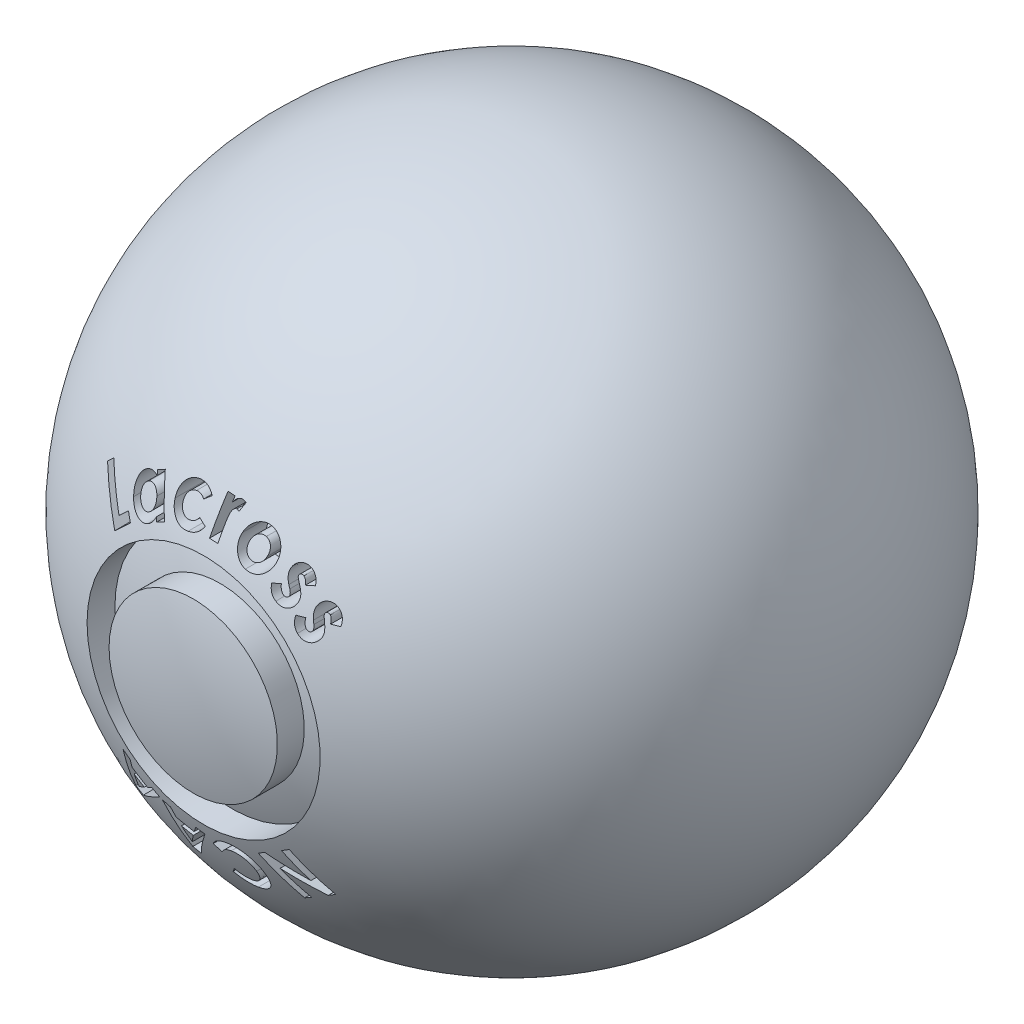
from build123d import *
from build123d.topology import SkipClean

# Parameters (mm, degrees)
LOGO_REACH      = 85.976
LOGO_END_RADIUS = 29.7942
SKETCH3_R       = 11.43
SKETCH3_R_2     = 8.255


with BuildPart() as part:
    # Sketch1 → base (revolve)
    with SkipClean():  # the faces are left unmerged after this step: merging them gives an invalid solid
        with BuildSketch(Plane.XY):
            with BuildLine():
                ThreePointArc((32.3342, 0), (22.863732084, 22.863732084), (0, 32.3342))
                Line((0, 32.3342), (0, -32.3342))
                ThreePointArc((0, -32.3342), (22.863732084, -22.863732084), (32.3342, 0))
            make_face()
            with BuildLine():
                Line((0, -32.3342), (0, 32.3342))
                ThreePointArc((0, 32.3342), (-32.3342, 0), (0, -32.3342))
            make_face()
        revolve(axis=Axis((0, 32.3342, 0), (0, -1, 0)))

    # logo: up to this sphere (the profile starts outside it)
    with SkipClean():  # the faces are left unmerged after this step: merging them gives an invalid solid
        logo_end = Location((0, 0, 0)) * Sphere(LOGO_END_RADIUS, mode=Mode.PRIVATE)
        # Sketch3 → logo (cut, up to the surface)
        with BuildSketch(Plane.XY.offset(38.1), mode=Mode.PRIVATE) as logo_sk1:
            with Locations(Location((0, 0, 0), (0, 0, 180))):
                Circle(SKETCH3_R)
            with Locations(Location((0, 0, 0), (0, 0, 180))):
                Circle(SKETCH3_R_2, mode=Mode.SUBTRACT)
        logo_tool1 = extrude(logo_sk1.sketch, amount=-LOGO_REACH, mode=Mode.PRIVATE) - logo_end
        add(logo_tool1.solids().sort_by_distance((11.106711, 0, 38.1))[0], mode=Mode.SUBTRACT)
        # Sketch3 → logo (cut, up to the surface)
        with BuildSketch(Plane.XY.offset(38.1), mode=Mode.PRIVATE) as logo_sk2:
            Polygon((-12.220194216, 11.952999391), (-11.59689694, 12.526432884), (-9.132201427, 9.846254599), (-8.223968254, 10.681472949), (-7.677247501, 10.086669263), (-9.20877795, 8.67801742), align=None)
        logo_tool2 = extrude(logo_sk2.sketch, amount=-LOGO_REACH, mode=Mode.PRIVATE) - logo_end
        add(logo_tool2.solids().sort_by_distance((-9.984775, 10.4692, 38.1))[0], mode=Mode.SUBTRACT)
        # Sketch3 → logo (cut, up to the surface)
        with BuildSketch(Plane.XY.offset(38.1), mode=Mode.PRIVATE) as logo_sk3:
            with BuildLine():
                Line((-6.575748347, 14.406590874), (-5.849161809, 14.784130938))
                Line((-5.849161809, 14.784130938), (-4.336330278, 11.877784784))
                Line((-4.336330278, 11.877784784), (-5.062916817, 11.50024472))
                Line((-5.062916817, 11.50024472), (-5.223193259, 11.807441234))
                add(Edge.make_bspline(
                    [(-5.223193259, 11.807441234), (-5.241626062, 11.756927378), (-5.277224447, 11.659372401), (-5.343199774, 11.522802371), (-5.415401381, 11.399777962), (-5.496691127, 11.290283693), (-5.586989432, 11.192801259), (-5.687387444, 11.105276293), (-5.798002488, 11.026348034), (-5.878076171, 10.982138714), (-5.918614934, 10.959756939)],
                    knots=[0, 0, 0, 0, 1.145109462, 2.21149471, 3.226674917, 4.180365656, 5.11119938, 6.052373645, 7.013978618, 8, 8, 8, 8], degree=3))
                add(Edge.make_bspline(
                    [(-5.918614934, 10.959756939), (-5.965704409, 10.937165483), (-6.058689034, 10.892555553), (-6.203905372, 10.842303191), (-6.35151192, 10.809393018), (-6.501364993, 10.792239337), (-6.653576791, 10.791612971), (-6.808523952, 10.806668483), (-6.965376421, 10.839671447), (-7.122933287, 10.886228428), (-7.276659987, 10.947900363), (-7.422704727, 11.024110008), (-7.559553322, 11.113269591), (-7.686635337, 11.216538136), (-7.804387818, 11.332558835), (-7.912772349, 11.461990517), (-8.012249912, 11.604492542), (-8.068748458, 11.707737443), (-8.097484125, 11.760248726)],
                    knots=[0, 0, 0, 0, 0.970234887, 1.915861843, 2.848753918, 3.776017437, 4.713904148, 5.672922253, 6.66399809, 7.688610075, 8.723316567, 9.737493544, 10.74587694, 11.75395846, 12.776057297, 13.813715798, 14.888036237, 16, 16, 16, 16], degree=3))
                add(Edge.make_bspline(
                    [(-8.097484125, 11.760248726), (-8.124898759, 11.815609134), (-8.178799867, 11.924455646), (-8.241032572, 12.092017225), (-8.290077093, 12.25770927), (-8.3184663, 12.422993037), (-8.333831545, 12.587124198), (-8.330701427, 12.75004546), (-8.312134103, 12.912094131), (-8.27632141, 13.070864421), (-8.227070437, 13.224193593), (-8.164381011, 13.368054335), (-8.090613026, 13.502131875), (-8.002590989, 13.624267163), (-7.903346281, 13.736622694), (-7.791133406, 13.837508705), (-7.666957866, 13.92849635), (-7.576290765, 13.978662921), (-7.530283604, 14.004118919)],
                    knots=[0, 0, 0, 0, 1.146589111, 2.254358864, 3.315174153, 4.351062424, 5.363677002, 6.372578805, 7.371537763, 8.387971139, 9.390331128, 10.358080331, 11.298261005, 12.226782769, 13.148291144, 14.077156464, 15.02429247, 16, 16, 16, 16], degree=3))
                add(Edge.make_bspline(
                    [(-7.530283604, 14.004118919), (-7.486714404, 14.025112987), (-7.400336498, 14.066734677), (-7.265419456, 14.114470966), (-7.127456306, 14.145015559), (-6.987702481, 14.163316919), (-6.845308343, 14.167008236), (-6.700760859, 14.154724526), (-6.55377864, 14.129580037), (-6.457366973, 14.100714208), (-6.408348508, 14.086037989)],
                    knots=[0, 0, 0, 0, 1.003475627, 1.98943578, 2.962432789, 3.931422823, 4.911339355, 5.912637565, 6.938724877, 8, 8, 8, 8], degree=3))
                Line((-6.408348508, 14.086037989), (-6.575748347, 14.406590874))
            make_face()
            with BuildLine():
                add(Edge.make_bspline(
                    [(-7.030755359, 13.409315233), (-7.058052705, 13.394064398), (-7.111746412, 13.364066105), (-7.186203033, 13.311469532), (-7.251900765, 13.252097941), (-7.311721841, 13.188885995), (-7.362674928, 13.118600322), (-7.405950905, 13.042839813), (-7.443300235, 12.962084502), (-7.470886849, 12.87613326), (-7.492055625, 12.7874909), (-7.501869801, 12.697257627), (-7.505746496, 12.606577076), (-7.496412645, 12.515441143), (-7.481189371, 12.423394458), (-7.454441783, 12.331268155), (-7.419938932, 12.238216448), (-7.390420831, 12.177627877), (-7.375349709, 12.146693037)],
                    knots=[0, 0, 0, 0, 1.024115946, 2.014429524, 2.978712035, 3.92142172, 4.860915671, 5.815042886, 6.77682121, 7.770138417, 8.7680152, 9.757134333, 10.739778378, 11.735567947, 12.752408901, 13.793014357, 14.873174473, 16, 16, 16, 16], degree=3))
                add(Edge.make_bspline(
                    [(-7.375349709, 12.146693037), (-7.358563278, 12.116463927), (-7.325586961, 12.057079974), (-7.269753918, 11.973966735), (-7.207574171, 11.899508634), (-7.140914567, 11.832638665), (-7.069414392, 11.773467302), (-6.992918283, 11.722442609), (-6.911943415, 11.678176845), (-6.825734099, 11.644439601), (-6.738102921, 11.617228636), (-6.649702573, 11.60024018), (-6.561933754, 11.593200999), (-6.475100486, 11.594873681), (-6.388887789, 11.605784085), (-6.303159195, 11.625320656), (-6.217918546, 11.654655203), (-6.163510969, 11.681575498), (-6.135878556, 11.695247725)],
                    knots=[0, 0, 0, 0, 1.125340342, 2.210688943, 3.253575218, 4.27840149, 5.280474548, 6.269324221, 7.267944258, 8.278090076, 9.277597838, 10.251608216, 11.201649133, 12.139077343, 13.073862727, 14.025474609, 14.997181906, 16, 16, 16, 16], degree=3))
                add(Edge.make_bspline(
                    [(-6.135878556, 11.695247725), (-6.107990907, 11.710803382), (-6.0534839, 11.741207246), (-5.977879321, 11.794042482), (-5.910501733, 11.853297238), (-5.851146728, 11.918555558), (-5.797639754, 11.988251138), (-5.753191668, 12.064375984), (-5.716675585, 12.146025719), (-5.687435128, 12.23216817), (-5.665929673, 12.321505378), (-5.654206754, 12.412880447), (-5.652884458, 12.505047115), (-5.659333369, 12.598294271), (-5.678400164, 12.691833459), (-5.703542026, 12.787016694), (-5.740675243, 12.882341079), (-5.771235356, 12.944728605), (-5.786832081, 12.976568838)],
                    knots=[0, 0, 0, 0, 1.028705706, 2.01062732, 2.966291609, 3.914120285, 4.84965696, 5.79298585, 6.747740096, 7.727842861, 8.720884071, 9.704481639, 10.689938034, 11.6877134, 12.710173653, 13.761403936, 14.857505237, 16, 16, 16, 16], degree=3))
                add(Edge.make_bspline(
                    [(-5.786832081, 12.976568838), (-5.803506529, 13.007167019), (-5.836223991, 13.067204675), (-5.893447988, 13.14989661), (-5.955162071, 13.224368823), (-6.021295505, 13.290596119), (-6.092006856, 13.349161607), (-6.168044202, 13.398891457), (-6.248530856, 13.441544872), (-6.333830031, 13.47348259), (-6.420586288, 13.499037787), (-6.508447926, 13.513881802), (-6.595848714, 13.520606491), (-6.683309124, 13.516625927), (-6.770681643, 13.504108195), (-6.858215184, 13.482816019), (-6.945609913, 13.451280393), (-7.001917353, 13.423528459), (-7.030755359, 13.409315233)],
                    knots=[0, 0, 0, 0, 1.131426828, 2.220008364, 3.260776545, 4.269884806, 5.256349188, 6.237852751, 7.216890221, 8.208946876, 9.19172847, 10.150808942, 11.098184545, 12.034304975, 12.988866843, 13.961759516, 14.95610973, 16, 16, 16, 16], degree=3))
            make_face(mode=Mode.SUBTRACT)
        logo_tool3 = extrude(logo_sk3.sketch, amount=-LOGO_REACH, mode=Mode.PRIVATE) - logo_end
        add(logo_tool3.solids().sort_by_distance((-6.186415, 14.545246, 38.1))[0], mode=Mode.SUBTRACT)
        # Sketch3 → logo (cut, up to the surface)
        with BuildSketch(Plane.XY.offset(38.1), mode=Mode.PRIVATE) as logo_sk4:
            with BuildLine():
                Line((-0.887055771, 15.204264211), (-1.495215827, 14.724325308))
                add(Edge.make_bspline(
                    [(-1.495215827, 14.724325308), (-1.531236286, 14.750302707), (-1.600157891, 14.800007904), (-1.707325266, 14.859864087), (-1.810707197, 14.906419163), (-1.913488852, 14.937239176), (-2.017526797, 14.955217444), (-2.126150101, 14.962271535), (-2.240998154, 14.957659223), (-2.318935088, 14.94645028), (-2.358927766, 14.940698506)],
                    knots=[0, 0, 0, 0, 1.157927751, 2.215580876, 3.196958254, 4.11086407, 5.007242523, 5.94639553, 6.946210253, 8, 8, 8, 8], degree=3))
                add(Edge.make_bspline(
                    [(-2.358927766, 14.940698506), (-2.395587857, 14.933949134), (-2.467274119, 14.920751206), (-2.570332141, 14.889962464), (-2.666575812, 14.851799169), (-2.756093352, 14.806307366), (-2.838883469, 14.753416693), (-2.914591114, 14.69272713), (-2.983866599, 14.624681015), (-3.044864828, 14.549054909), (-3.097899818, 14.468363037), (-3.143163634, 14.384344756), (-3.17781015, 14.296736128), (-3.203275063, 14.205755229), (-3.217858121, 14.111303736), (-3.22435059, 14.013556001), (-3.220697104, 13.912744575), (-3.211358134, 13.845117653), (-3.206612061, 13.810749587)],
                    knots=[0, 0, 0, 0, 1.126958784, 2.203689632, 3.247420436, 4.255315036, 5.236623827, 6.213981355, 7.185381852, 8.168373322, 9.14704971, 10.103015897, 11.050043467, 11.991093346, 12.954995786, 13.935688241, 14.950914819, 16, 16, 16, 16], degree=3))
                add(Edge.make_bspline(
                    [(-3.206612061, 13.810749587), (-3.200083815, 13.77736484), (-3.187299449, 13.711986967), (-3.158403997, 13.618166662), (-3.122994751, 13.530233798), (-3.079218135, 13.448604915), (-3.026857763, 13.373657918), (-2.96850055, 13.303466263), (-2.900566551, 13.241315517), (-2.827301359, 13.184038116), (-2.747294897, 13.135562985), (-2.663014734, 13.094941854), (-2.574568546, 13.063880508), (-2.4823942, 13.041517038), (-2.386356365, 13.02823971), (-2.28648784, 13.023694034), (-2.182825465, 13.029414975), (-2.113112581, 13.03913564), (-2.077553567, 13.044093938)],
                    knots=[0, 0, 0, 0, 1.063594057, 2.082852897, 3.065721664, 4.02542117, 4.973278218, 5.922044483, 6.874665232, 7.847880727, 8.827278234, 9.794985254, 10.770015254, 11.754199014, 12.757471331, 13.798491988, 14.877059044, 16, 16, 16, 16], degree=3))
                add(Edge.make_bspline(
                    [(-2.077553567, 13.044093938), (-2.034004239, 13.052401777), (-1.948836839, 13.068649032), (-1.82756247, 13.10750495), (-1.715093204, 13.15552082), (-1.612417067, 13.214170328), (-1.519407949, 13.283880305), (-1.435672586, 13.36323151), (-1.360410664, 13.452745625), (-1.319849024, 13.519589726), (-1.299322398, 13.553416855)],
                    knots=[0, 0, 0, 0, 1.10374896, 2.158550613, 3.165502063, 4.146038512, 5.097044931, 6.054327365, 7.015372806, 8, 8, 8, 8], degree=3))
                Line((-1.299322398, 13.553416855), (-0.592325202, 13.225740573))
                add(Edge.make_bspline(
                    [(-0.592325202, 13.225740573), (-0.62737299, 13.164832686), (-0.696305076, 13.045038886), (-0.824078853, 12.883238537), (-0.967931202, 12.74009535), (-1.128739844, 12.6152888), (-1.306247104, 12.50941634), (-1.501392532, 12.424491081), (-1.712397879, 12.355610181), (-1.860786763, 12.326889887), (-1.936866468, 12.312164852)],
                    knots=[0, 0, 0, 0, 0.998240525, 1.963342229, 2.921403494, 3.87798527, 4.85087333, 5.85242791, 6.898929304, 8, 8, 8, 8], degree=3))
                add(Edge.make_bspline(
                    [(-1.936866468, 12.312164852), (-2.005892356, 12.302048093), (-2.140506613, 12.282318394), (-2.339954901, 12.273679497), (-2.530112353, 12.282251677), (-2.71186019, 12.307954206), (-2.884888205, 12.351282759), (-3.049205671, 12.41314979), (-3.204042373, 12.492980299), (-3.348689009, 12.589121997), (-3.481298404, 12.698212219), (-3.600934547, 12.81631616), (-3.708007767, 12.940860111), (-3.798992234, 13.074831951), (-3.877215912, 13.215858981), (-3.940065562, 13.365633623), (-3.991208264, 13.522381579), (-4.011834214, 13.631190455), (-4.022241067, 13.686090132)],
                    knots=[0, 0, 0, 0, 1.196219795, 2.332867314, 3.418648779, 4.45776986, 5.476632145, 6.472497083, 7.463141199, 8.458784809, 9.446532586, 10.404307894, 11.339912548, 12.259359812, 13.17779133, 14.101809662, 15.042265299, 16, 16, 16, 16], degree=3))
                add(Edge.make_bspline(
                    [(-4.022241067, 13.686090132), (-4.028133434, 13.724608724), (-4.039831665, 13.801080437), (-4.047581617, 13.916291973), (-4.047409985, 14.030194089), (-4.040570959, 14.143284493), (-4.025136695, 14.255063802), (-4.003191378, 14.36587018), (-3.972410561, 14.475257513), (-3.934367388, 14.583234729), (-3.889142421, 14.688838965), (-3.837283275, 14.790487557), (-3.779675464, 14.888468682), (-3.712847637, 14.980391645), (-3.642388484, 15.070268023), (-3.562974893, 15.153706175), (-3.478603182, 15.234415747), (-3.386894208, 15.309504033), (-3.290381303, 15.380046999), (-3.188070424, 15.443056104), (-3.08258139, 15.501073401), (-2.97238417, 15.552423442), (-2.85732233, 15.595196424), (-2.739084285, 15.634039715), (-2.61619422, 15.665421828), (-2.532364853, 15.680833554), (-2.489820194, 15.688655236)],
                    knots=[0, 0, 0, 0, 0.995950414, 1.97727983, 2.948640864, 3.906749746, 4.871596994, 5.831537396, 6.79264694, 7.77429907, 8.756801484, 9.727450811, 10.69053567, 11.659165654, 12.631000869, 13.608154772, 14.601238803, 15.614671913, 16.63625518, 17.655439798, 18.684437337, 19.713210985, 20.760404607, 21.821149039, 22.894200504, 24, 24, 24, 24], degree=3))
                add(Edge.make_bspline(
                    [(-2.489820194, 15.688655236), (-2.450408296, 15.694825585), (-2.372432073, 15.707033585), (-2.255771442, 15.715884139), (-2.141415437, 15.721121003), (-2.028950562, 15.718470632), (-1.918768165, 15.708155731), (-1.810360249, 15.693637692), (-1.704320781, 15.670914656), (-1.600161354, 15.64268851), (-1.498905323, 15.607784607), (-1.400512708, 15.567949552), (-1.306154563, 15.521362266), (-1.215167998, 15.469648055), (-1.127424275, 15.412666111), (-1.043606516, 15.348862814), (-0.962528298, 15.280081738), (-0.912238584, 15.22956214), (-0.887055771, 15.204264211)],
                    knots=[0, 0, 0, 0, 1.097199944, 2.170804075, 3.216940276, 4.246237457, 5.262886345, 6.260763493, 7.253816715, 8.2444155, 9.228394006, 10.198996497, 11.163221881, 12.121480209, 13.077369194, 14.039413266, 15.018226851, 16, 16, 16, 16], degree=3))
            make_face()
        logo_tool4 = extrude(logo_sk4.sketch, amount=-LOGO_REACH, mode=Mode.PRIVATE) - logo_end
        add(logo_tool4.solids().sort_by_distance((-1.221354, 15.002585, 38.1))[0], mode=Mode.SUBTRACT)
        # Sketch3 → logo (cut, up to the surface)
        with BuildSketch(Plane.XY.offset(38.1), mode=Mode.PRIVATE) as logo_sk5:
            with BuildLine():
                Line((0.269653378, 15.956382691), (0.973088875, 15.915423156))
                Line((0.973088875, 15.915423156), (0.949047409, 15.504046954))
                add(Edge.make_bspline(
                    [(0.949047409, 15.504046954), (0.971046214, 15.541408518), (1.013852513, 15.614108388), (1.090710203, 15.711227038), (1.177049345, 15.792237901), (1.271268906, 15.857931831), (1.37169517, 15.907586317), (1.476527895, 15.942126385), (1.585031905, 15.960677226), (1.65835664, 15.959597058), (1.69522329, 15.959053965)],
                    knots=[0, 0, 0, 0, 1.124591015, 2.188281535, 3.202140693, 4.187434691, 5.159108903, 6.099583294, 7.044497103, 8, 8, 8, 8], degree=3))
                add(Edge.make_bspline(
                    [(1.69522329, 15.959053965), (1.722071377, 15.956569148), (1.777073148, 15.951478681), (1.858882919, 15.92858921), (1.942687054, 15.897720276), (1.996767952, 15.869460063), (2.024680422, 15.854874277)],
                    knots=[0, 0, 0, 0, 0.927313302, 1.899720982, 2.915994776, 4, 4, 4, 4], degree=3))
                Line((2.024680422, 15.854874277), (1.728169003, 15.163014301))
                add(Edge.make_bspline(
                    [(1.728169003, 15.163014301), (1.706095815, 15.175268157), (1.66448406, 15.198368783), (1.603225837, 15.225103984), (1.547518923, 15.243622613), (1.511608741, 15.247553872), (1.494877737, 15.249385495)],
                    knots=[0, 0, 0, 0, 1.207154316, 2.275693477, 3.196623997, 4, 4, 4, 4], degree=3))
                add(Edge.make_bspline(
                    [(1.494877737, 15.249385495), (1.479401326, 15.249667654), (1.448459949, 15.250231762), (1.402748431, 15.240651278), (1.358413552, 15.224332675), (1.315528267, 15.20095375), (1.273986006, 15.170303664), (1.234999293, 15.131252203), (1.196496708, 15.085445141), (1.158438504, 15.031574227), (1.123140547, 14.966126924), (1.09254366, 14.887052645), (1.065381812, 14.794336838), (1.041492442, 14.687191663), (1.020786509, 14.565878705), (1.001642802, 14.430270317), (0.988138097, 14.28044952), (0.981176498, 14.175844482), (0.977540999, 14.121217426)],
                    knots=[0, 0, 0, 0, 0.546632639, 1.092860965, 1.641510706, 2.215257216, 2.816456664, 3.463070312, 4.164189625, 4.933951345, 5.794571111, 6.789939713, 7.930528933, 9.213034544, 10.674862598, 12.287591142, 14.061298296, 16, 16, 16, 16], degree=3))
                Line((0.977540999, 14.121217426), (0.971308026, 13.961831409))
                Line((0.971308026, 13.961831409), (0.894731503, 12.63955076))
                Line((0.894731503, 12.63955076), (0.080883346, 12.686743268))
                Line((0.080883346, 12.686743268), (0.269653378, 15.956382691))
            make_face()
        logo_tool5 = extrude(logo_sk5.sketch, amount=-LOGO_REACH, mode=Mode.PRIVATE) - logo_end
        add(logo_tool5.solids().sort_by_distance((0.747111, 14.517672, 38.1))[0], mode=Mode.SUBTRACT)
        # Sketch3 → logo (cut, up to the surface)
        with BuildSketch(Plane.XY.offset(38.1), mode=Mode.PRIVATE) as logo_sk6:
            with BuildLine():
                add(Edge.make_bspline(
                    [(4.697901306, 15.187179607), (4.734299747, 15.1752246), (4.806481436, 15.151516645), (4.911176894, 15.107020095), (5.012506837, 15.057564685), (5.11012746, 15.001504457), (5.20282228, 14.937409042), (5.29286113, 14.868501919), (5.378413104, 14.79220166), (5.460304761, 14.710813612), (5.536023408, 14.6236853), (5.607158554, 14.534206881), (5.669085718, 14.440002172), (5.72583941, 14.34340038), (5.775693496, 14.243311409), (5.817413612, 14.13914399), (5.853206859, 14.032508181), (5.881606037, 13.922985226), (5.902741414, 13.812022734), (5.917482292, 13.700838496), (5.922949045, 13.589846773), (5.924095368, 13.479151955), (5.914026287, 13.368614877), (5.899541995, 13.257846867), (5.876347784, 13.147479227), (5.855320042, 13.074970056), (5.844768293, 13.038584856)],
                    knots=[0, 0, 0, 0, 1.018394457, 2.019576417, 3.022064227, 4.015751269, 5.009657713, 6.016888229, 7.028931562, 8.055854414, 9.08495886, 10.09703297, 11.093068232, 12.079929621, 13.075339233, 14.063210134, 15.061588094, 16.06472819, 17.069357639, 18.064015951, 19.044290168, 20.023006146, 21.004899576, 21.992770477, 22.992769484, 24, 24, 24, 24], degree=3))
                add(Edge.make_bspline(
                    [(5.844768293, 13.038584856), (5.832806489, 13.002189267), (5.809085053, 12.930013232), (5.764792322, 12.825521205), (5.715211074, 12.724809363), (5.658730753, 12.628265286), (5.596195784, 12.535552684), (5.527873157, 12.446026072), (5.451553976, 12.361911979), (5.371061863, 12.280666836), (5.285170595, 12.205649474), (5.195635994, 12.136701666), (5.103116083, 12.074063882), (5.006437881, 12.018933684), (4.906725356, 11.969668779), (4.803150972, 11.927712535), (4.696144798, 11.893327519), (4.586822853, 11.864672701), (4.475622381, 11.843221266), (4.363431583, 11.829736547), (4.250965201, 11.824987551), (4.138253844, 11.825288062), (4.025162127, 11.834303779), (3.911945755, 11.851564108), (3.798290015, 11.875422512), (3.723361105, 11.896893199), (3.685488445, 11.907745513)],
                    knots=[0, 0, 0, 0, 1.016057447, 2.014941895, 3.008067243, 3.992663983, 4.979871014, 5.973745371, 6.97758402, 7.991013701, 9.006643836, 10.000518193, 10.987725224, 11.968377692, 12.950956943, 13.93656088, 14.93018563, 15.931023722, 16.933347748, 17.932573584, 18.925917451, 19.918168238, 20.921358042, 21.932582482, 22.955028186, 24, 24, 24, 24], degree=3))
                add(Edge.make_bspline(
                    [(3.685488445, 11.907745513), (3.631072615, 11.926312389), (3.523847192, 11.962898089), (3.371656774, 12.034830829), (3.230421525, 12.119750028), (3.099427096, 12.217221512), (2.979494775, 12.328317064), (2.870706132, 12.452748023), (2.772178292, 12.589824756), (2.686025284, 12.738137496), (2.612966977, 12.893803498), (2.557202313, 13.053605761), (2.515934275, 13.214622398), (2.49423272, 13.378049354), (2.487565374, 13.542981487), (2.498858039, 13.709969014), (2.525802898, 13.878689471), (2.557365601, 13.989529205), (2.573348021, 14.045655168)],
                    knots=[0, 0, 0, 0, 1.028686203, 2.027007824, 3.006615811, 3.974743282, 4.944837264, 5.927553025, 6.928825655, 7.962276475, 8.993977351, 10.002288768, 10.988159783, 11.964303085, 12.948009538, 13.938380803, 14.956057024, 16, 16, 16, 16], degree=3))
                add(Edge.make_bspline(
                    [(2.573348021, 14.045655168), (2.593611724, 14.104852134), (2.633451127, 14.221236179), (2.711353899, 14.386018941), (2.80445341, 14.537776587), (2.912946811, 14.676015787), (3.034367613, 14.802682419), (3.171199088, 14.915335566), (3.321849604, 15.016101638), (3.431354221, 15.070521224), (3.486923742, 15.098137139)],
                    knots=[0, 0, 0, 0, 1.04412101, 2.052791475, 3.036212205, 4.010714058, 4.981567237, 5.96001797, 6.964784992, 8, 8, 8, 8], degree=3))
                add(Edge.make_bspline(
                    [(3.486923742, 15.098137139), (3.536743609, 15.119783031), (3.634883794, 15.162423286), (3.786012838, 15.210556553), (3.937467255, 15.24367085), (4.089179218, 15.262804148), (4.241586314, 15.266034805), (4.394239318, 15.255476054), (4.547284106, 15.229799939), (4.647373593, 15.201477496), (4.697901306, 15.187179607)],
                    knots=[0, 0, 0, 0, 1.047996384, 2.06444866, 3.055608472, 4.036967183, 5.011192551, 5.993286812, 6.986960247, 8, 8, 8, 8], degree=3))
            make_face()
            with BuildLine():
                add(Edge.make_bspline(
                    [(4.481528109, 14.447236699), (4.451707858, 14.455923747), (4.39300142, 14.473025738), (4.303293348, 14.486769288), (4.215049092, 14.492392562), (4.128210243, 14.488791729), (4.042732046, 14.476451415), (3.958945462, 14.453875967), (3.876404373, 14.422349011), (3.795925992, 14.382404119), (3.718722526, 14.33512177), (3.648257212, 14.278894883), (3.582484474, 14.217902322), (3.524868811, 14.14827949), (3.471689686, 14.073390852), (3.425509562, 13.990901157), (3.38521549, 13.901815801), (3.364101144, 13.838984395), (3.35336004, 13.807021354)],
                    knots=[0, 0, 0, 0, 1.025659295, 2.01919172, 2.992217562, 3.944648992, 4.886716554, 5.840965218, 6.806643618, 7.80259493, 8.807158111, 9.792373054, 10.777832195, 11.766411737, 12.773462886, 13.810228875, 14.886038887, 16, 16, 16, 16], degree=3))
                add(Edge.make_bspline(
                    [(3.35336004, 13.807021354), (3.343888859, 13.773619776), (3.325360546, 13.708276822), (3.307693854, 13.609906923), (3.298490908, 13.514288386), (3.298419415, 13.420954084), (3.307245755, 13.329965654), (3.325106054, 13.241336811), (3.351967177, 13.155393214), (3.387563378, 13.072791658), (3.430803724, 12.994887669), (3.48119554, 12.923218752), (3.537126328, 12.857358627), (3.601397521, 12.800038768), (3.669541187, 12.746274945), (3.746481361, 12.702119493), (3.829047008, 12.663674108), (3.887411706, 12.643611886), (3.916998862, 12.633441627)],
                    knots=[0, 0, 0, 0, 1.140648367, 2.23143151, 3.279900529, 4.294551675, 5.294461344, 6.279843708, 7.261112126, 8.248810089, 9.231484024, 10.184206767, 11.124965334, 12.064103649, 13.010511257, 13.972628984, 14.972253032, 16, 16, 16, 16], degree=3))
                add(Edge.make_bspline(
                    [(3.916998862, 12.633441627), (3.947117248, 12.624753378), (4.006425301, 12.607644788), (4.09672637, 12.593959878), (4.185552404, 12.588284367), (4.272697369, 12.591827207), (4.358738579, 12.604327504), (4.443119899, 12.6268136), (4.526355709, 12.658125686), (4.607057433, 12.69828581), (4.684564643, 12.745810132), (4.755705825, 12.802301557), (4.820930927, 12.865202275), (4.881536043, 12.933693571), (4.933602276, 13.010871655), (4.980017239, 13.0944083), (5.02170361, 13.184238507), (5.042551727, 13.248180653), (5.053180753, 13.280780369)],
                    knots=[0, 0, 0, 0, 1.026345414, 2.021042844, 2.985801708, 3.939860148, 4.873923758, 5.829468657, 6.796040197, 7.783529752, 8.779558009, 9.7700612, 10.753854886, 11.746695692, 12.761172226, 13.797608873, 14.877151791, 16, 16, 16, 16], degree=3))
                add(Edge.make_bspline(
                    [(5.053180753, 13.280780369), (5.062661538, 13.313583181), (5.081279857, 13.378001182), (5.098861707, 13.475226514), (5.107961638, 13.570231546), (5.108539813, 13.662774077), (5.097927426, 13.752696698), (5.080929884, 13.840444385), (5.05232802, 13.925345632), (5.01726003, 14.007892525), (4.974005836, 14.086032291), (4.922674025, 14.157534912), (4.865758112, 14.222921444), (4.801792524, 14.281404805), (4.731112657, 14.332959), (4.654353076, 14.378597202), (4.570755517, 14.417307044), (4.511717719, 14.437110162), (4.481528109, 14.447236699)],
                    knots=[0, 0, 0, 0, 1.123129589, 2.205596382, 3.245582722, 4.261436162, 5.244110079, 6.22108757, 7.197185737, 8.186054055, 9.169892393, 10.129378895, 11.077662836, 12.017913967, 12.975210312, 13.951845938, 14.952654473, 16, 16, 16, 16], degree=3))
            make_face(mode=Mode.SUBTRACT)
        logo_tool6 = extrude(logo_sk6.sketch, amount=-LOGO_REACH, mode=Mode.PRIVATE) - logo_end
        add(logo_tool6.solids().sort_by_distance((5.677656, 14.327574, 38.1))[0], mode=Mode.SUBTRACT)
        # Sketch3 → logo (cut, up to the surface)
        with BuildSketch(Plane.XY.offset(38.1), mode=Mode.PRIVATE) as logo_sk7:
            with BuildLine():
                Line((9.120872804, 12.48881759), (8.422779855, 12.330321997))
                add(Edge.make_bspline(
                    [(8.422779855, 12.330321997), (8.41421995, 12.364250446), (8.397806243, 12.429308594), (8.368528124, 12.522073803), (8.334802458, 12.605250993), (8.29827191, 12.680337549), (8.257782517, 12.746323444), (8.212759762, 12.802579606), (8.165675315, 12.851477086), (8.129681806, 12.87639321), (8.112021642, 12.888618271)],
                    knots=[0, 0, 0, 0, 1.283551009, 2.461222165, 3.565211269, 4.573206879, 5.521944952, 6.397708381, 7.21383792, 8, 8, 8, 8], degree=3))
                add(Edge.make_bspline(
                    [(8.112021642, 12.888618271), (8.093284481, 12.899516527), (8.057709346, 12.920208398), (8.002599526, 12.942005669), (7.949739116, 12.954397523), (7.899397634, 12.955288988), (7.85400682, 12.947099674), (7.813017207, 12.932791587), (7.7801513, 12.906343849), (7.763433598, 12.884533946), (7.754961346, 12.873481051)],
                    knots=[0, 0, 0, 0, 1.307415728, 2.482312613, 3.565150663, 4.569013402, 5.497223871, 6.342662493, 7.160089049, 8, 8, 8, 8], degree=3))
                add(Edge.make_bspline(
                    [(7.754961346, 12.873481051), (7.745652786, 12.853728344), (7.726498783, 12.813083665), (7.727922016, 12.75128782), (7.745136696, 12.695080383), (7.771382172, 12.637553289), (7.809792094, 12.566300517), (7.840522776, 12.514518046), (7.857360184, 12.486146316)],
                    knots=[0, 0, 0, 0, 0.922575234, 1.898361234, 2.544163898, 3.429429864, 4.591578978, 6, 6, 6, 6], degree=3))
                Line((7.857360184, 12.486146316), (8.030992996, 12.199429569))
                add(Edge.make_bspline(
                    [(8.030992996, 12.199429569), (8.052886143, 12.162759976), (8.095203628, 12.091880952), (8.153029326, 11.986662307), (8.200480126, 11.885020503), (8.241920135, 11.789081802), (8.275444864, 11.697659312), (8.300323117, 11.610738437), (8.317750222, 11.528341805), (8.329665384, 11.425723147), (8.326681022, 11.300754606), (8.301225576, 11.153423565), (8.24853496, 11.009289349), (8.197092325, 10.919497734), (8.170789671, 10.873587221)],
                    knots=[0, 0, 0, 0, 1.083638643, 2.094576033, 3.044544634, 3.928583737, 4.745712387, 5.513273275, 6.220737076, 6.880239256, 8.130572748, 9.377385926, 10.65905568, 12, 12, 12, 12], degree=3))
                add(Edge.make_bspline(
                    [(8.170789671, 10.873587221), (8.150846023, 10.844107511), (8.111662543, 10.786188439), (8.044587453, 10.707318574), (7.970951475, 10.638249679), (7.891277169, 10.5781632), (7.805437966, 10.527389061), (7.713885756, 10.485214056), (7.616383282, 10.452007525), (7.513323904, 10.429432481), (7.407223767, 10.415600062), (7.299196324, 10.414352981), (7.190154168, 10.422670328), (7.080315251, 10.444954528), (6.969767512, 10.47698631), (6.858215523, 10.520203846), (6.74620728, 10.575586879), (6.673090259, 10.61957888), (6.635697524, 10.642076804)],
                    knots=[0, 0, 0, 0, 0.980659576, 1.926711384, 2.847080871, 3.758569697, 4.672076108, 5.59098966, 6.532821563, 7.505495485, 8.494990011, 9.476979896, 10.478545359, 11.503924383, 12.560399588, 13.648343707, 14.797340756, 16, 16, 16, 16], degree=3))
                add(Edge.make_bspline(
                    [(6.635697524, 10.642076804), (6.587426454, 10.674572758), (6.493231055, 10.737984846), (6.367376997, 10.849176579), (6.25797377, 10.969586984), (6.165610428, 11.100578735), (6.089926912, 11.241217736), (6.033239601, 11.392652582), (5.991348896, 11.553211828), (5.978148121, 11.664649329), (5.971440713, 11.721271516)],
                    knots=[0, 0, 0, 0, 1.059955634, 2.068380595, 3.053004735, 4.019863193, 4.983384507, 5.956205925, 6.961533692, 8, 8, 8, 8], degree=3))
                Line((5.971440713, 11.721271516), (6.690013429, 11.916274521))
                add(Edge.make_bspline(
                    [(6.690013429, 11.916274521), (6.696102751, 11.880196773), (6.708215813, 11.808429832), (6.739408151, 11.704051986), (6.778345894, 11.602765247), (6.826811642, 11.507290553), (6.880983225, 11.420163554), (6.938673942, 11.34517061), (6.998263616, 11.282660526), (7.042701631, 11.251107201), (7.063991794, 11.235990066)],
                    knots=[0, 0, 0, 0, 1.101363585, 2.190865564, 3.275217944, 4.36695608, 5.411495159, 6.361250451, 7.214878364, 8, 8, 8, 8], degree=3))
                add(Edge.make_bspline(
                    [(7.063991794, 11.235990066), (7.086229089, 11.223198378), (7.129081937, 11.198547885), (7.195910129, 11.173044601), (7.26174293, 11.161182315), (7.324835425, 11.160857797), (7.382949236, 11.172078), (7.433483213, 11.192972993), (7.476313678, 11.22215343), (7.495934416, 11.249280684), (7.505642435, 11.262702806)],
                    knots=[0, 0, 0, 0, 1.257167274, 2.422650779, 3.487797947, 4.521438035, 5.500748256, 6.368648294, 7.192833875, 8, 8, 8, 8], degree=3))
                add(Edge.make_bspline(
                    [(7.505642435, 11.262702806), (7.513206709, 11.276667449), (7.52863247, 11.305145427), (7.538353522, 11.355135821), (7.540387901, 11.410226472), (7.530370667, 11.470716258), (7.511953049, 11.536448661), (7.485076103, 11.608205395), (7.447222779, 11.685168505), (7.417205791, 11.737471116), (7.401462748, 11.764902325)],
                    knots=[0, 0, 0, 0, 0.706622447, 1.441009236, 2.251274611, 3.163745644, 4.168601004, 5.30289484, 6.585446228, 8, 8, 8, 8], degree=3))
                Line((7.401462748, 11.764902325), (7.24207673, 12.027577606))
                add(Edge.make_bspline(
                    [(7.24207673, 12.027577606), (7.207057074, 12.089001429), (7.139954751, 12.206697652), (7.06216025, 12.385701142), (7.006923354, 12.556424269), (6.97812993, 12.720015159), (6.971179034, 12.875885646), (6.991526522, 13.024135156), (7.034204065, 13.165428092), (7.082503052, 13.250296796), (7.106732179, 13.292871075)],
                    knots=[0, 0, 0, 0, 1.263092236, 2.420252865, 3.482439696, 4.462864465, 5.381279065, 6.259185759, 7.126722699, 8, 8, 8, 8], degree=3))
                add(Edge.make_bspline(
                    [(7.106732179, 13.292871075), (7.12426012, 13.319126896), (7.159090995, 13.371301489), (7.220729572, 13.440881163), (7.287487338, 13.503630065), (7.360302293, 13.557845937), (7.439954144, 13.603745512), (7.525080176, 13.641639935), (7.616212158, 13.672480799), (7.71231044, 13.694071687), (7.811507572, 13.708002321), (7.911463376, 13.709972966), (8.011119733, 13.704304776), (8.110543987, 13.687158594), (8.209430881, 13.658808784), (8.308758101, 13.622701315), (8.407147614, 13.574978382), (8.47055713, 13.536761844), (8.502918076, 13.517258095)],
                    knots=[0, 0, 0, 0, 0.959601437, 1.906884427, 2.820640487, 3.74363292, 4.662196382, 5.612187681, 6.574632262, 7.584589836, 8.605111814, 9.616965418, 10.621416448, 11.638455884, 12.67927595, 13.747934477, 14.850661903, 16, 16, 16, 16], degree=3))
                add(Edge.make_bspline(
                    [(8.502918076, 13.517258095), (8.546489287, 13.488066692), (8.63271253, 13.430299709), (8.747034266, 13.324906692), (8.849504923, 13.209172562), (8.936308461, 13.080652564), (9.008557449, 12.943287853), (9.065360637, 12.798764812), (9.103204428, 12.646254726), (9.114922946, 12.541834839), (9.120872804, 12.48881759)],
                    knots=[0, 0, 0, 0, 1.009909998, 1.99851494, 2.988047092, 3.984900174, 4.980717752, 5.975482285, 6.972088916, 8, 8, 8, 8], degree=3))
            make_face()
        logo_tool7 = extrude(logo_sk7.sketch, amount=-LOGO_REACH, mode=Mode.PRIVATE) - logo_end
        add(logo_tool7.solids().sort_by_distance((7.583834, 12.038345, 38.1))[0], mode=Mode.SUBTRACT)
        # Sketch3 → logo (cut, up to the surface)
        with BuildSketch(Plane.XY.offset(38.1), mode=Mode.PRIVATE) as logo_sk8:
            with BuildLine():
                Line((11.596869832, 10.253114683), (10.877406691, 10.24866256))
                add(Edge.make_bspline(
                    [(10.877406691, 10.24866256), (10.876241186, 10.283700212), (10.873995517, 10.351209937), (10.865619859, 10.448581626), (10.850585498, 10.537596977), (10.830024446, 10.618597832), (10.80474781, 10.691646672), (10.773187758, 10.756837204), (10.73644281, 10.814115739), (10.706613492, 10.846510345), (10.692198358, 10.862165164)],
                    knots=[0, 0, 0, 0, 1.28190688, 2.469948007, 3.570907967, 4.579150874, 5.523188725, 6.392109292, 7.222980575, 8, 8, 8, 8], degree=3))
                add(Edge.make_bspline(
                    [(10.692198358, 10.862165164), (10.676273066, 10.877187219), (10.646016741, 10.905727493), (10.596510501, 10.939170804), (10.546971975, 10.962307043), (10.49782561, 10.973915686), (10.451224448, 10.975912181), (10.408158441, 10.969135255), (10.3690803, 10.951906784), (10.34834627, 10.933141098), (10.337809336, 10.923604467)],
                    knots=[0, 0, 0, 0, 1.308589125, 2.486177306, 3.559449417, 4.56344284, 5.487902025, 6.334862473, 7.153785116, 8, 8, 8, 8], degree=3))
                add(Edge.make_bspline(
                    [(10.337809336, 10.923604467), (10.324409813, 10.906269877), (10.296743597, 10.870478862), (10.285849571, 10.809347092), (10.290126346, 10.750074032), (10.303960199, 10.687983442), (10.32526752, 10.609440906), (10.344844301, 10.552479572), (10.355617829, 10.521132512)],
                    knots=[0, 0, 0, 0, 0.919615349, 1.898745103, 2.542810306, 3.442772553, 4.592702131, 6, 6, 6, 6], degree=3))
                Line((10.355617829, 10.521132512), (10.465140065, 10.202360476))
                add(Edge.make_bspline(
                    [(10.465140065, 10.202360476), (10.478863647, 10.16181286), (10.505450631, 10.08325911), (10.53807816, 9.967221907), (10.56527995, 9.857789295), (10.585131339, 9.75436646), (10.59746896, 9.657388334), (10.604284074, 9.566722437), (10.603717381, 9.482379675), (10.592856644, 9.379001742), (10.56458222, 9.256721659), (10.506295141, 9.11815309), (10.424671253, 8.987606125), (10.3548006, 8.910540819), (10.319110417, 8.87117558)],
                    knots=[0, 0, 0, 0, 1.080966754, 2.094179643, 3.043245898, 3.928309955, 4.752111971, 5.511048139, 6.223230122, 6.878883095, 8.133534647, 9.37675795, 10.660038436, 12, 12, 12, 12], degree=3))
                add(Edge.make_bspline(
                    [(10.319110417, 8.87117558), (10.293478309, 8.84657615), (10.242900596, 8.798036136), (10.159362151, 8.735645451), (10.072304679, 8.683073827), (9.981441164, 8.640387168), (9.886240457, 8.609421316), (9.787233267, 8.587750017), (9.684198504, 8.577492615), (9.578374801, 8.576527311), (9.471442228, 8.585918382), (9.364954688, 8.607855889), (9.26027281, 8.640750708), (9.156835038, 8.684971365), (9.055479182, 8.74015715), (8.955939304, 8.807307883), (8.856817896, 8.884010648), (8.795071176, 8.943297794), (8.763538502, 8.973574419)],
                    knots=[0, 0, 0, 0, 0.97456864, 1.923035417, 2.855120087, 3.762845287, 4.672433763, 5.597798299, 6.539943767, 7.509629032, 8.499642499, 9.480831119, 10.488493037, 11.507066627, 12.564467209, 13.65149814, 14.800672409, 16, 16, 16, 16], degree=3))
                add(Edge.make_bspline(
                    [(8.763538502, 8.973574419), (8.72304127, 9.015729027), (8.643971258, 9.098035031), (8.5444523, 9.234497736), (8.462865463, 9.376202515), (8.3999045, 9.524428636), (8.355569065, 9.678681364), (8.332396148, 9.839413862), (8.325130205, 10.00613571), (8.335958085, 10.118416615), (8.341477204, 10.175647736)],
                    knots=[0, 0, 0, 0, 1.059189176, 2.068045058, 3.054241492, 4.019094331, 4.981842472, 5.956333247, 6.958314956, 8, 8, 8, 8], degree=3))
                Line((8.341477204, 10.175647736), (9.08854351, 10.213045572))
                add(Edge.make_bspline(
                    [(9.08854351, 10.213045572), (9.086848807, 10.176232684), (9.083482692, 10.103112867), (9.092670064, 9.994087629), (9.108973088, 9.886342749), (9.136468429, 9.782116752), (9.171419486, 9.685137852), (9.21089291, 9.598503685), (9.2570934, 9.525268301), (9.29367965, 9.484537775), (9.31114968, 9.465088842)],
                    knots=[0, 0, 0, 0, 1.103690336, 2.192211431, 3.273287813, 4.367503927, 5.417369528, 6.360780588, 7.217268427, 8, 8, 8, 8], degree=3))
                add(Edge.make_bspline(
                    [(9.31114968, 9.465088842), (9.330254251, 9.447570919), (9.366799516, 9.414060764), (9.427219802, 9.375203664), (9.488521505, 9.348584226), (9.550276884, 9.33483827), (9.609203221, 9.334344463), (9.663408494, 9.34245233), (9.711441995, 9.363031953), (9.736687127, 9.385403399), (9.749238622, 9.396526141)],
                    knots=[0, 0, 0, 0, 1.265499969, 2.420783672, 3.493556124, 4.518237085, 5.490616374, 6.359006127, 7.184122836, 8, 8, 8, 8], degree=3))
                add(Edge.make_bspline(
                    [(9.749238622, 9.396526141), (9.759754253, 9.408526889), (9.781284176, 9.433097473), (9.800685352, 9.480452516), (9.814719402, 9.533674586), (9.818107318, 9.595123067), (9.814320042, 9.663732626), (9.802117191, 9.739937444), (9.782536016, 9.823573883), (9.764202285, 9.881036543), (9.754581171, 9.911191606)],
                    knots=[0, 0, 0, 0, 0.706691722, 1.446895482, 2.252332944, 3.154441686, 4.174570578, 5.312247219, 6.589530049, 8, 8, 8, 8], degree=3))
                Line((9.754581171, 9.911191606), (9.653963182, 10.203250901))
                add(Edge.make_bspline(
                    [(9.653963182, 10.203250901), (9.632358854, 10.270839449), (9.590942599, 10.400409066), (9.553851682, 10.593120642), (9.53641601, 10.772751932), (9.541809023, 10.940027243), (9.570387658, 11.094360891), (9.620102651, 11.236311521), (9.693940968, 11.365304401), (9.759153695, 11.438715662), (9.791979007, 11.475667768)],
                    knots=[0, 0, 0, 0, 1.260007094, 2.415477773, 3.479911498, 4.461678345, 5.379288938, 6.258500276, 7.123403128, 8, 8, 8, 8], degree=3))
                add(Edge.make_bspline(
                    [(9.791979007, 11.475667768), (9.815063735, 11.497442794), (9.860653078, 11.540445646), (9.934827577, 11.597397642), (10.014559662, 11.643277702), (10.097530324, 11.681376407), (10.185054523, 11.708603621), (10.276112305, 11.728811099), (10.372022, 11.738097327), (10.470902654, 11.7387472), (10.570987281, 11.731576271), (10.669439549, 11.711911896), (10.766211985, 11.685026956), (10.859669928, 11.645849635), (10.951598012, 11.598649809), (11.040097684, 11.540211243), (11.127658949, 11.473319782), (11.181797725, 11.421882724), (11.209535097, 11.395529547)],
                    knots=[0, 0, 0, 0, 0.961450866, 1.898740706, 2.825919435, 3.743801586, 4.659786601, 5.598370385, 6.565903125, 7.57337823, 8.593026894, 9.600341368, 10.611023724, 11.631624145, 12.665574551, 13.738390269, 14.841290591, 16, 16, 16, 16], degree=3))
                add(Edge.make_bspline(
                    [(11.209535097, 11.395529547), (11.245842473, 11.357486593), (11.317731286, 11.282161327), (11.407882773, 11.154748723), (11.482997259, 11.019224997), (11.541858828, 10.875475893), (11.583912982, 10.72550079), (11.60790822, 10.571027629), (11.614050933, 10.412448178), (11.602655462, 10.30676925), (11.596869832, 10.253114683)],
                    knots=[0, 0, 0, 0, 1.007459426, 1.994775426, 2.98337061, 3.973881472, 4.966940822, 5.963664399, 6.966125916, 8, 8, 8, 8], degree=3))
            make_face()
        logo_tool8 = extrude(logo_sk8.sketch, amount=-LOGO_REACH, mode=Mode.PRIVATE) - logo_end
        add(logo_tool8.solids().sort_by_distance((9.991662, 10.14082, 38.1))[0], mode=Mode.SUBTRACT)
        # Sketch3 → logo (cut, up to the surface)
        with BuildSketch(Plane.XY.offset(38.1), mode=Mode.PRIVATE) as logo_sk9:
            Polygon((-8.58212869, -14.550057864), (-9.300701406, -14.097722127), (-8.388906534, -9.470185068), (-7.6516349, -9.934096326), (-7.84396663, -10.885069884), (-6.324902127, -11.841385989), (-5.537766711, -11.265281222), (-4.800495076, -11.72919248), align=None)
            Polygon((-8.323905533, -13.332847327), (-7.022995076, -12.36673655), (-8.01314732, -11.743439275), align=None, mode=Mode.SUBTRACT)
        logo_tool9 = extrude(logo_sk9.sketch, amount=-LOGO_REACH, mode=Mode.PRIVATE) - logo_end
        add(logo_tool9.solids().sort_by_distance((-8.905261, -14.266457, 38.1))[0], mode=Mode.SUBTRACT)
        # Sketch3 → logo (cut, up to the surface)
        with BuildSketch(Plane.XY.offset(38.1), mode=Mode.PRIVATE) as logo_sk10:
            Polygon((-2.910626366, -16.673719362), (-3.747625564, -16.506319522), (-4.550788625, -11.834261229), (-3.692419234, -12.006113192), (-3.532142792, -12.967771846), (-1.762868954, -13.321270443), (-1.229504571, -12.497627615), (-0.37113518, -12.669479578), align=None)
            Polygon((-3.10562937, -15.438700331), (-2.229451486, -14.064775051), (-3.382551446, -13.834155059), align=None, mode=Mode.SUBTRACT)
        logo_tool10 = extrude(logo_sk10.sketch, amount=-LOGO_REACH, mode=Mode.PRIVATE) - logo_end
        add(logo_tool10.solids().sort_by_distance((-3.316585, -16.527316, 38.1))[0], mode=Mode.SUBTRACT)
        # Sketch3 → logo (cut, up to the surface)
        with BuildSketch(Plane.XY.offset(38.1), mode=Mode.PRIVATE) as logo_sk11:
            with BuildLine():
                Line((0.598176326, -16.23828871), (1.080786502, -15.586497845))
                add(Edge.make_bspline(
                    [(1.080786502, -15.586497845), (1.138556309, -15.627639993), (1.251353743, -15.707971381), (1.428656588, -15.807847842), (1.606841908, -15.8879484), (1.786297775, -15.948165199), (1.967512569, -15.987897296), (2.14997512, -16.006478107), (2.333783304, -16.005429042), (2.455128044, -15.988552563), (2.516151086, -15.980065553)],
                    knots=[0, 0, 0, 0, 1.11053214, 2.168350257, 3.182055217, 4.167288373, 5.128638251, 6.082275841, 7.035595929, 8, 8, 8, 8], degree=3))
                add(Edge.make_bspline(
                    [(2.516151086, -15.980065553), (2.56685838, -15.970085764), (2.666787915, -15.950418462), (2.810212684, -15.904082981), (2.946029709, -15.847746345), (3.071568465, -15.776181141), (3.190612986, -15.69522794), (3.299947865, -15.60028688), (3.401286436, -15.493501626), (3.49301727, -15.375946618), (3.573709801, -15.250272911), (3.641073439, -15.119227528), (3.692504657, -14.983702963), (3.731722395, -14.845316141), (3.754255487, -14.702455218), (3.764473587, -14.556131023), (3.759116997, -14.40541778), (3.744411181, -14.304776371), (3.736923321, -14.2535321)],
                    knots=[0, 0, 0, 0, 1.051077812, 2.071372955, 3.06217696, 4.038602306, 5.007202687, 5.98815912, 6.979570748, 7.999561782, 9.018478764, 10.015470477, 10.99269915, 11.964478393, 12.937815051, 13.930826814, 14.946424986, 16, 16, 16, 16], degree=3))
                add(Edge.make_bspline(
                    [(3.736923321, -14.2535321), (3.730193549, -14.218128792), (3.716875225, -14.148065089), (3.690193256, -14.04533127), (3.656963683, -13.946891556), (3.619857449, -13.852073104), (3.576936317, -13.761974497), (3.52878492, -13.675762962), (3.474011253, -13.594300537), (3.415892291, -13.515547413), (3.351494904, -13.442944732), (3.283467255, -13.374780993), (3.211761954, -13.311643998), (3.135483293, -13.254318533), (3.055144599, -13.202518262), (2.970495261, -13.156400685), (2.881946614, -13.115126406), (2.758844386, -13.068052764), (2.599003376, -13.022913402), (2.400206413, -12.995576796), (2.195605294, -12.992879927), (2.059215014, -13.012238145), (1.9899101, -13.022074768)],
                    knots=[0, 0, 0, 0, 0.902491353, 1.786044619, 2.655886335, 3.503523879, 4.334867092, 5.153717762, 5.974355104, 6.792125139, 7.603381138, 8.40241852, 9.203183254, 9.994191304, 10.790179444, 11.59531499, 12.406877502, 13.235257035, 14.894699355, 16.553758619, 18.248838086, 20, 20, 20, 20], degree=3))
                add(Edge.make_bspline(
                    [(1.9899101, -13.022074768), (1.931468545, -13.034031983), (1.816721607, -13.05750935), (1.6512237, -13.11120397), (1.497351211, -13.182026826), (1.376225188, -13.25281753), (1.284549517, -13.320123388), (1.214327903, -13.376735701), (1.143992822, -13.441093051), (1.073347231, -13.51305988), (1.001789558, -13.591792229), (0.92916248, -13.677801403), (0.856630329, -13.771163852), (0.808755069, -13.836401298), (0.784275084, -13.869759063)],
                    knots=[0, 0, 0, 0, 1.413429609, 2.775195183, 4.113379411, 5.422671499, 6.09259553, 6.807979016, 7.560068917, 8.351170708, 9.19792211, 10.081721841, 11.019129715, 12, 12, 12, 12], degree=3))
                Line((0.784275084, -13.869759063), (0.123579972, -13.383587188))
                add(Edge.make_bspline(
                    [(0.123579972, -13.383587188), (0.15647109, -13.338797941), (0.220726013, -13.251299254), (0.3208996, -13.127428576), (0.420585861, -13.012404766), (0.51993638, -12.906164599), (0.620060928, -12.810230509), (0.718602663, -12.721956195), (0.818620738, -12.644958619), (0.918418412, -12.575134774), (1.020940186, -12.51334628), (1.127468793, -12.457097937), (1.238546917, -12.405496413), (1.354484647, -12.359158823), (1.475275959, -12.318283197), (1.600569603, -12.281730432), (1.731077772, -12.250488695), (1.820060091, -12.233680758), (1.865250645, -12.22514468)],
                    knots=[0, 0, 0, 0, 1.237288611, 2.417123246, 3.546253459, 4.626344766, 5.654701118, 6.633365945, 7.570717721, 8.463602899, 9.344345447, 10.234290271, 11.145073923, 12.070488906, 13.013138596, 13.983668006, 14.975985777, 16, 16, 16, 16], degree=3))
                add(Edge.make_bspline(
                    [(1.865250645, -12.22514468), (1.948191148, -12.21262753), (2.110498998, -12.188132482), (2.352650146, -12.178020669), (2.5864549, -12.188873134), (2.812460632, -12.223240726), (3.030566012, -12.277962036), (3.240483124, -12.356446816), (3.442499477, -12.456221542), (3.633779974, -12.578602761), (3.813360477, -12.717024424), (3.975173093, -12.873084459), (4.11962512, -13.043166788), (4.245801428, -13.228388722), (4.352881196, -13.428837018), (4.440963503, -13.644101612), (4.512086098, -13.87353782), (4.543612476, -14.033249774), (4.559675725, -14.11462585)],
                    knots=[0, 0, 0, 0, 1.089531519, 2.132124983, 3.144072457, 4.127190384, 5.098368397, 6.061429557, 7.034444605, 8.021166102, 9.008098721, 9.976645258, 10.937354805, 11.903539977, 12.883838379, 13.885349773, 14.922548169, 16, 16, 16, 16], degree=3))
                add(Edge.make_bspline(
                    [(4.559675725, -14.11462585), (4.56802813, -14.167966482), (4.584538508, -14.273406052), (4.597987401, -14.431362277), (4.600123412, -14.586590914), (4.594728264, -14.738949944), (4.577253712, -14.888226048), (4.551013007, -15.034785039), (4.512863095, -15.178154018), (4.467226926, -15.318911933), (4.410656709, -15.455239834), (4.345856903, -15.587202438), (4.271502239, -15.714104143), (4.18840626, -15.836265916), (4.096848405, -15.954350644), (3.994595062, -16.066065345), (3.885182073, -16.174644784), (3.766253189, -16.276055866), (3.640985624, -16.371027934), (3.511256686, -16.458670477), (3.376655195, -16.536124341), (3.237534532, -16.604030529), (3.094731432, -16.663863581), (2.947026167, -16.713575781), (2.795455916, -16.755122156), (2.692013304, -16.774999388), (2.639920116, -16.785009463)],
                    knots=[0, 0, 0, 0, 1.058818214, 2.092988659, 3.106150212, 4.102529285, 5.081059269, 6.051694528, 7.02038979, 7.988787593, 8.952096933, 9.912851936, 10.870426559, 11.834439353, 12.809203844, 13.798447666, 14.802957815, 15.830997622, 16.861490772, 17.885218943, 18.899801304, 19.904834324, 20.920084613, 21.93451663, 22.959832798, 24, 24, 24, 24], degree=3))
                add(Edge.make_bspline(
                    [(2.639920116, -16.785009463), (2.595164969, -16.792007772), (2.506224348, -16.805915309), (2.371855459, -16.81843524), (2.237464131, -16.822734101), (2.102869804, -16.819731171), (1.968450907, -16.811391263), (1.834050325, -16.794283131), (1.699952094, -16.768768818), (1.565569575, -16.738430174), (1.433515057, -16.698928551), (1.304252311, -16.653497109), (1.17779648, -16.602073696), (1.055735012, -16.541801307), (0.935348669, -16.477411141), (0.819980655, -16.403475933), (0.70652944, -16.32486065), (0.634367344, -16.267204599), (0.598176326, -16.23828871)],
                    knots=[0, 0, 0, 0, 0.99701957, 1.981348441, 2.968492346, 3.955290219, 4.944054537, 5.931954965, 6.935376696, 7.948136133, 8.963232345, 9.967525868, 10.963688708, 11.966003661, 12.963023231, 13.967274245, 14.980539387, 16, 16, 16, 16], degree=3))
            make_face()
        logo_tool11 = extrude(logo_sk11.sketch, amount=-LOGO_REACH, mode=Mode.PRIVATE) - logo_end
        add(logo_tool11.solids().sort_by_distance((0.891292, -15.950756, 38.1))[0], mode=Mode.SUBTRACT)
        # Sketch3 → logo (cut, up to the surface)
        with BuildSketch(Plane.XY.offset(38.1), mode=Mode.PRIVATE) as logo_sk12:
            Polygon((10.198254593, -13.631454033), (9.504613767, -14.046391934), (6.372099745, -12.519313609), (7.871574905, -15.024078232), (7.146769216, -15.458605476), (4.868172461, -11.652039971), (5.56448456, -11.234430796), (8.689875185, -12.756166573), (7.194852149, -10.258525347), (7.919657838, -9.824888529), align=None)
        logo_tool12 = extrude(logo_sk12.sketch, amount=-LOGO_REACH, mode=Mode.PRIVATE) - logo_end
        add(logo_tool12.solids().sort_by_distance((7.532633, -12.640859, 38.1))[0], mode=Mode.SUBTRACT)


solid = part.part
